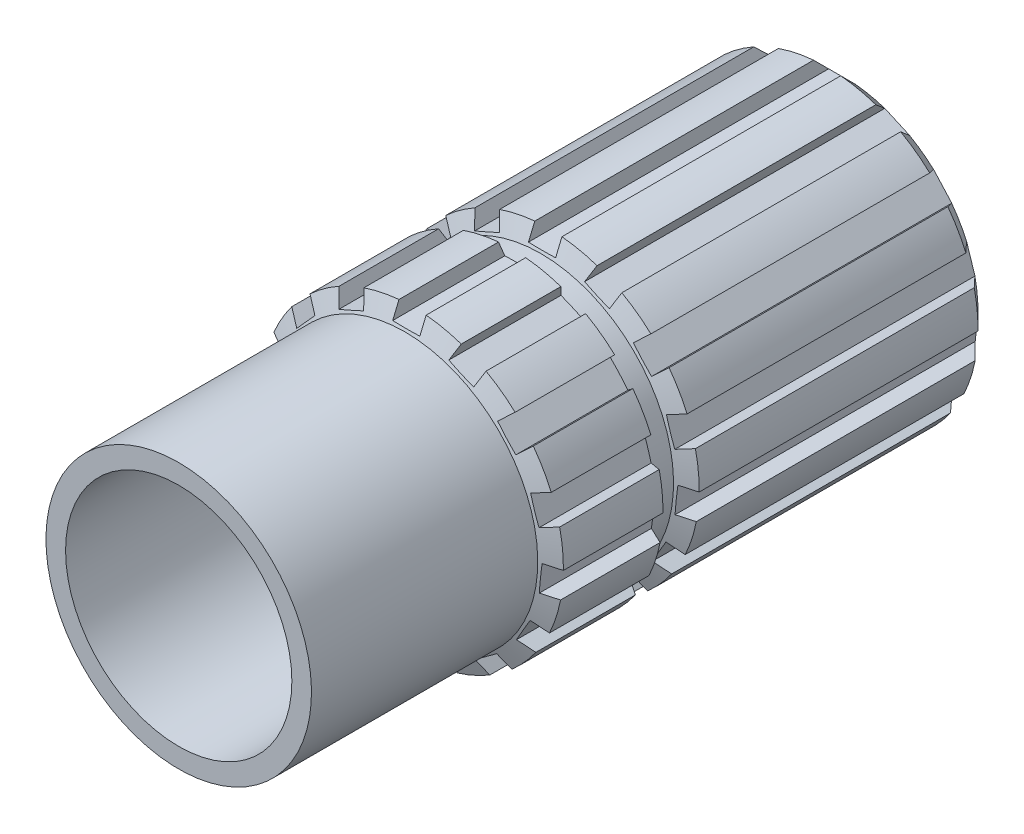
from build123d import *

# Parameters (mm, degrees)
CHAMFER1_SIZE      = 1.27
SKETCH3_OUTSIDE_W  = 40.682
SKETCH3_OUTSIDE_H  = 40.682
CUT_EXTRUDE3_DEPTH = 56.857134854


with BuildPart() as part:
    # Sketch2 → Revolve1 (revolve)
    with BuildSketch(Plane(origin=(0, 0, 0), x_dir=(0, 0, -1), z_dir=(1, 0, 0))):
        Polygon((-27.928567427, 9.525), (27.928567427, 9.525), (27.928567427, 12.7), (3.186432573, 12.7), (2.551432573, 11.176), (0.773432573, 11.176), (0.138432573, 12.7), (-8.243567427, 12.7), (-8.878567427, 11.176), (-27.928567427, 11.176), align=None)
    revolve(axis=Axis((0, 0, 0), (0, 0, 1)))

    # Chamfer1
    chamfer1_edges = [part.edges().sort_by_distance(p)[0] for p in [
        (0, -12.7, -27.928567427),
    ]]
    chamfer(chamfer1_edges, length=CHAMFER1_SIZE)

    # Sketch3 outside → Cut-Extrude3 (cut, through all)
    with BuildSketch(Plane(origin=(0, 0, -27.928567427), x_dir=(-1, 0, 0), z_dir=(0, 0, -1))):
        Rectangle(SKETCH3_OUTSIDE_W, SKETCH3_OUTSIDE_H)
        with BuildLine():
            Line((-1.143, 11.37846042), (1.143, 11.37846042))
            Line((1.143, 11.37846042), (1.143, 12.64846042))
            ThreePointArc((1.143, 12.64846042), (2.640478473, 12.422474529), (4.100409873, 12.019843546))
            Line((4.100409873, 12.019843546), (3.583854337, 10.859640815))
            Line((3.583854337, 10.859640815), (5.672219253, 9.929840849))
            Line((5.672219253, 9.929840849), (6.188774789, 11.09004358))
            ThreePointArc((6.188774789, 11.09004358), (7.464872704, 10.274515829), (8.634821628, 9.312886526))
            Line((8.634821628, 9.312886526), (7.6910277, 8.463090656))
            Line((7.6910277, 8.463090656), (9.220660266, 6.764261585))
            Line((9.220660266, 6.764261585), (10.164454195, 7.614057455))
            ThreePointArc((10.164454195, 7.614057455), (10.998522628, 6.35), (11.676194279, 4.995646821))
            Line((11.676194279, 4.995646821), (10.468352503, 4.603195238))
            Line((10.468352503, 4.603195238), (11.174765353, 2.429080042))
            Line((11.174765353, 2.429080042), (12.382607128, 2.821531624))
            ThreePointArc((12.382607128, 2.821531624), (12.630428071, 1.327511483), (12.698646864, -0.185385604))
            Line((12.698646864, -0.185385604), (11.435604057, -0.052634456))
            Line((11.435604057, -0.052634456), (11.19665199, -2.326111508))
            Line((11.19665199, -2.326111508), (12.459694797, -2.458862657))
            ThreePointArc((12.459694797, -2.458862657), (12.078417757, -3.924515829), (11.525388043, -5.334363174))
            Line((11.525388043, -5.334363174), (10.42553578, -4.699363174))
            Line((10.42553578, -4.699363174), (9.28253578, -6.679097247))
            Line((9.28253578, -6.679097247), (10.382388043, -7.314097247))
            ThreePointArc((10.382388043, -7.314097247), (9.437939284, -8.497958701), (8.359284924, -9.560980889))
            Line((8.359284924, -9.560980889), (7.612797653, -8.533529306))
            Line((7.612797653, -8.533529306), (5.763384804, -9.877206393))
            Line((5.763384804, -9.877206393), (6.509872075, -10.904657976))
            ThreePointArc((6.509872075, -10.904657976), (5.165555367, -11.602027312), (3.7477855, -12.13441815))
            Line((3.7477855, -12.13441815), (3.483737652, -10.892170697))
            Line((3.483737652, -10.892170697), (1.247692237, -11.367456823))
            Line((1.247692237, -11.367456823), (1.511740085, -12.609704276))
            ThreePointArc((1.511740085, -12.609704276), (0, -12.7), (-1.511740085, -12.609704276))
            Line((-1.511740085, -12.609704276), (-1.247692237, -11.367456823))
            Line((-1.247692237, -11.367456823), (-3.483737652, -10.892170697))
            Line((-3.483737652, -10.892170697), (-3.7477855, -12.13441815))
            ThreePointArc((-3.7477855, -12.13441815), (-5.165555367, -11.602027312), (-6.509872075, -10.904657976))
            Line((-6.509872075, -10.904657976), (-5.763384804, -9.877206393))
            Line((-5.763384804, -9.877206393), (-7.612797653, -8.533529306))
            Line((-7.612797653, -8.533529306), (-8.359284924, -9.560980889))
            ThreePointArc((-8.359284924, -9.560980889), (-9.437939284, -8.497958701), (-10.382388043, -7.314097247))
            Line((-10.382388043, -7.314097247), (-9.28253578, -6.679097247))
            Line((-9.28253578, -6.679097247), (-10.42553578, -4.699363174))
            Line((-10.42553578, -4.699363174), (-11.525388043, -5.334363174))
            ThreePointArc((-11.525388043, -5.334363174), (-12.078417757, -3.924515829), (-12.459694797, -2.458862657))
            Line((-12.459694797, -2.458862657), (-11.19665199, -2.326111508))
            Line((-11.19665199, -2.326111508), (-11.435604057, -0.052634456))
            Line((-11.435604057, -0.052634456), (-12.698646864, -0.185385604))
            ThreePointArc((-12.698646864, -0.185385604), (-12.630428071, 1.327511483), (-12.382607128, 2.821531624))
            Line((-12.382607128, 2.821531624), (-11.174765353, 2.429080042))
            Line((-11.174765353, 2.429080042), (-10.468352503, 4.603195238))
            Line((-10.468352503, 4.603195238), (-11.676194279, 4.995646821))
            ThreePointArc((-11.676194279, 4.995646821), (-10.998522628, 6.35), (-10.164454195, 7.614057455))
            Line((-10.164454195, 7.614057455), (-9.220660266, 6.764261585))
            Line((-9.220660266, 6.764261585), (-7.6910277, 8.463090656))
            Line((-7.6910277, 8.463090656), (-8.634821628, 9.312886526))
            ThreePointArc((-8.634821628, 9.312886526), (-7.464872704, 10.274515829), (-6.188774789, 11.09004358))
            Line((-6.188774789, 11.09004358), (-5.672219253, 9.929840849))
            Line((-5.672219253, 9.929840849), (-3.583854337, 10.859640815))
            Line((-3.583854337, 10.859640815), (-4.100409873, 12.019843546))
            ThreePointArc((-4.100409873, 12.019843546), (-2.640478473, 12.422474529), (-1.143, 12.64846042))
            Line((-1.143, 12.64846042), (-1.143, 11.37846042))
        make_face(mode=Mode.SUBTRACT)
    extrude(amount=-CUT_EXTRUDE3_DEPTH, mode=Mode.SUBTRACT)


solid = part.part
